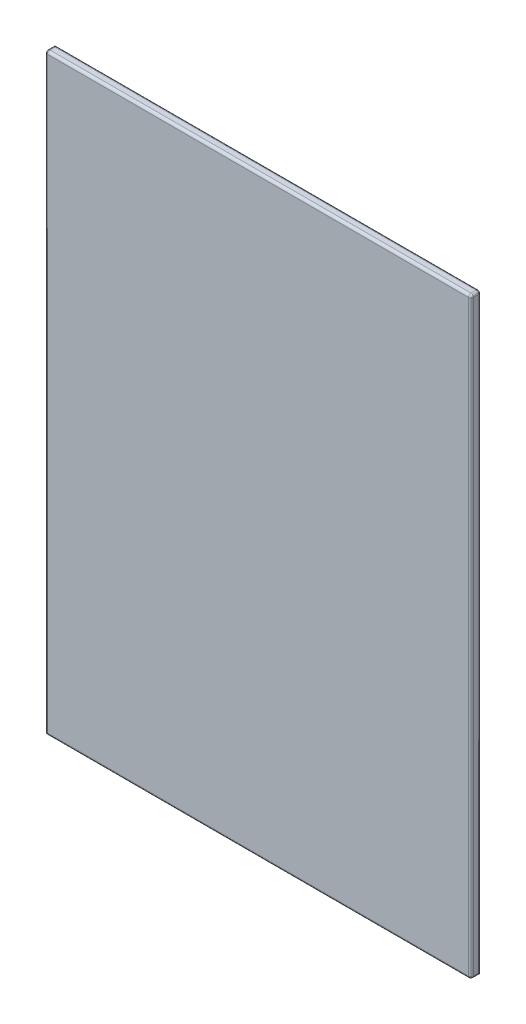
from build123d import *

# Parameters (mm, degrees)
SKETCH1_W           = 855
SKETCH1_H           = 1190
BOSS_EXTRUDE1_DEPTH = 20
FILLET1_R           = 5


with BuildPart() as part:
    # Sketch1 → Boss-Extrude1 (new body)
    with BuildSketch(Plane.XY):
        Rectangle(SKETCH1_W, SKETCH1_H)
    extrude(amount=BOSS_EXTRUDE1_DEPTH)

    # Fillet1
    fillet1_edges = [part.edges().sort_by_distance(p)[0] for p in [
        (-427.5, 0, 20),
        (0, -595, 20),
        (427.5, 0, 20),
        (0, 595, 0),
        (427.5, 0, 0),
        (427.5, -595, 10),
        (-427.5, 595, 10),
        (427.5, 595, 10),
        (0, 595, 20),
    ]]
    fillet(fillet1_edges, radius=FILLET1_R)


solid = part.part
